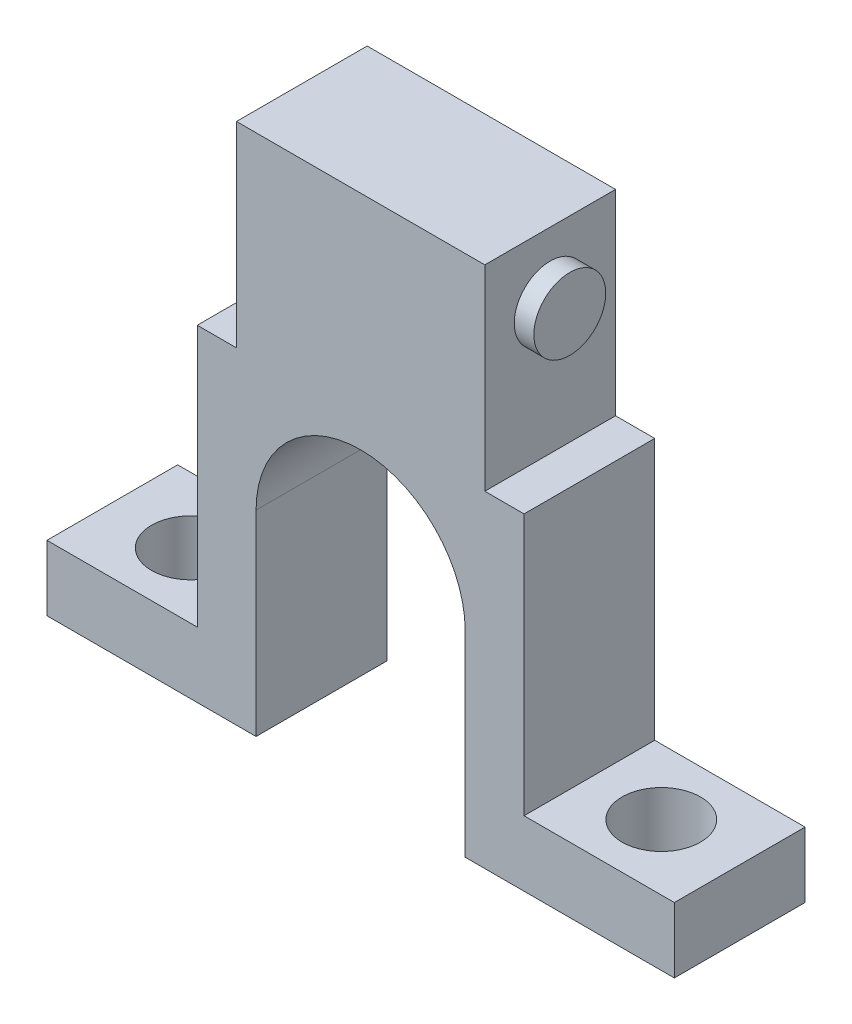
from build123d import *

# Parameters (mm, degrees)
BOSS_EXTRUDE1_DEPTH = 5
SKETCH4_R           = 2.75
BOSS_EXTRUDE3_DEPTH = 11
SKETCH6_W           = 48
SKETCH6_H           = 10
BOSS_EXTRUDE4_DEPTH = 5
SKETCH7_R           = 3
CUT_EXTRUDE2_DEPTH  = 6
CUT_EXTRUDE3_DEPTH  = 11


with BuildPart() as part:
    # Sketch1 → Boss-Extrude1 (new body, symmetric)
    with BuildSketch(Plane.XY):
        Polygon((-9.5, 17.5), (9.5, 17.5), (9.5, 2.5), (12.5, 2.5), (12.5, -17.5), (-12.5, -17.5), (-12.5, 2.5), (-9.5, 2.5), align=None)
    extrude(amount=BOSS_EXTRUDE1_DEPTH, both=True)

    # Sketch4 → Boss-Extrude3 (add, symmetric)
    with BuildSketch(Plane(origin=(0, 0, 0), x_dir=(0, 0, -1), z_dir=(1, 0, 0))):
        with Locations((0, 12.5)):
            Circle(SKETCH4_R)
    extrude(amount=BOSS_EXTRUDE3_DEPTH, both=True)

    # Sketch6 → Boss-Extrude4 (add)
    with BuildSketch(Plane.XZ.offset(17.5)):
        Rectangle(SKETCH6_W, SKETCH6_H)
    extrude(amount=BOSS_EXTRUDE4_DEPTH)

    # Sketch7 → Cut-Extrude2 (cut, through all)
    with BuildSketch(Plane(origin=(0, -17.5, 0), x_dir=(1, 0, 0), z_dir=(0, 1, 0))):
        with Locations((-18, 0)):
            Circle(SKETCH7_R)
        with Locations((18, 0)):
            Circle(SKETCH7_R)
    extrude(amount=-CUT_EXTRUDE2_DEPTH, mode=Mode.SUBTRACT)

    # Sketch8 → Cut-Extrude3 (cut, through all)
    with BuildSketch(Plane.XY.offset(5)):
        with BuildLine():
            Line((-8, -22.5), (-8, -7.5))
            ThreePointArc((-8, -7.5), (0, 0.5), (8, -7.5))
            Line((8, -7.5), (8, -22.5))
            ThreePointArc((8, -22.5), (0, -30.5), (-8, -22.5))
        make_face()
    extrude(amount=-CUT_EXTRUDE3_DEPTH, mode=Mode.SUBTRACT)


solid = part.part
